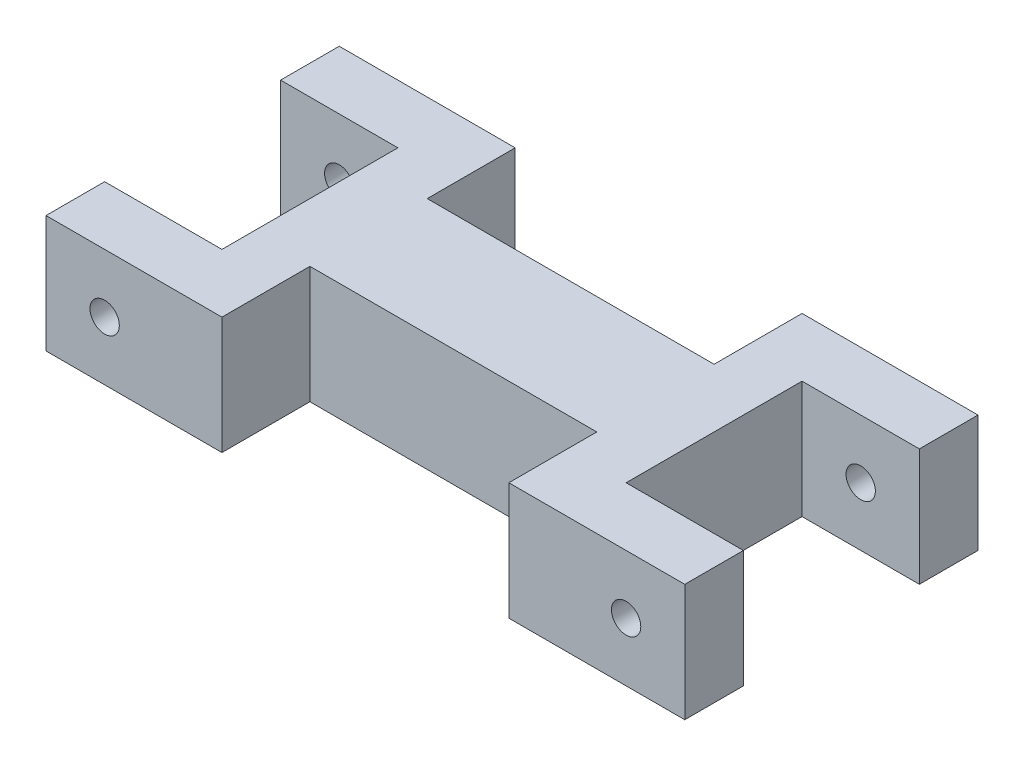
from build123d import *

# Parameters (mm, degrees)
BOSS_EXTRUDE1_DEPTH = 12.7
SKETCH2_R           = 1.5875
CUT_EXTRUDE1_DEPTH  = 32.75


with BuildPart() as part:
    # Sketch1 → Boss-Extrude1 (new body)
    with BuildSketch(Plane(origin=(0, 0, 0), x_dir=(1, 0, 0), z_dir=(0, 1, 0))):
        Polygon((0, 9.525), (-12.7, 9.525), (-12.7, 15.875), (6.35, 15.875), (6.35, 6.35), (37.410945752, 6.35), (37.410945752, 15.875), (56.460945752, 15.875), (56.460945752, 9.525), (43.760945752, 9.525), (43.760945752, -9.525), (56.460945752, -9.525), (56.460945752, -15.875), (37.410945752, -15.875), (37.410945752, -6.35), (6.35, -6.35), (6.35, -15.875), (-12.7, -15.875), (-12.7, -9.525), (0, -9.525), align=None)
    extrude(amount=BOSS_EXTRUDE1_DEPTH)

    # Sketch2 → Cut-Extrude1 (cut, through all)
    with BuildSketch(Plane.XY.offset(15.875)):
        with Locations((50.110945752, 6.35)):
            Circle(SKETCH2_R)
        with Locations((-6.35, 6.35)):
            Circle(SKETCH2_R)
    extrude(amount=-CUT_EXTRUDE1_DEPTH, mode=Mode.SUBTRACT)


solid = part.part
